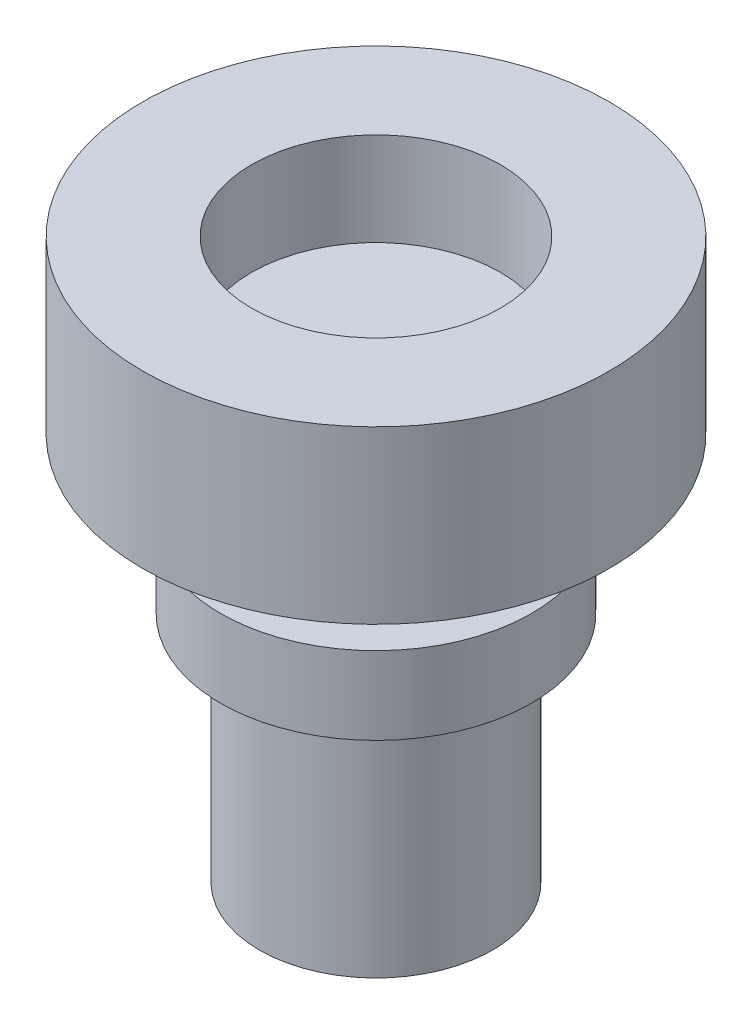
from build123d import *

# Parameters (mm, degrees)
SKETCH1_R           = 3
SKETCH1_R_2         = 1.6
BOSS_EXTRUDE1_DEPTH = 2.2
SKETCH1_3_R         = 1.6
BOSS_EXTRUDE2_DEPTH = 1
SKETCH5_R           = 1.5
BOSS_EXTRUDE3_DEPTH = 1
SKETCH6_R           = 2
BOSS_EXTRUDE4_DEPTH = 1
SKETCH8_R           = 1.5
BOSS_EXTRUDE5_DEPTH = 3


with BuildPart() as part:
    # Sketch1 → Boss-Extrude1 (new body)
    with BuildSketch(Plane(origin=(0, 0, 0), x_dir=(1, 0, 0), z_dir=(0, 1, 0))):
        with Locations((-0.522013312, 0.511138034)):
            Circle(SKETCH1_R)
        with Locations((-0.522013312, 0.511138034)):
            Circle(SKETCH1_R_2, mode=Mode.SUBTRACT)
    extrude(amount=BOSS_EXTRUDE1_DEPTH)

    # Sketch1_3 → Boss-Extrude2 (add)
    with BuildSketch(Plane(origin=(0, 0, 0), x_dir=(1, 0, 0), z_dir=(0, 1, 0))):
        with Locations((-0.522013312, 0.511138034)):
            Circle(SKETCH1_3_R)
    extrude(amount=BOSS_EXTRUDE2_DEPTH)

    # Sketch5 → Boss-Extrude3 (add)
    with BuildSketch(Plane.XZ):
        with Locations((-0.522013312, -0.511138034)):
            Circle(SKETCH5_R)
    extrude(amount=BOSS_EXTRUDE3_DEPTH)

    # Sketch6 → Boss-Extrude4 (add)
    with BuildSketch(Plane.XZ.offset(1)):
        with Locations((-0.522013312, -0.511138034)):
            Circle(SKETCH6_R)
    extrude(amount=BOSS_EXTRUDE4_DEPTH)

    # Sketch8 → Boss-Extrude5 (add)
    with BuildSketch(Plane(origin=(0, -2, 0), x_dir=(-1, 0, 0), z_dir=(0, -1, 0))):
        with Locations((0.522013312, 0.511138034)):
            Circle(SKETCH8_R)
    extrude(amount=BOSS_EXTRUDE5_DEPTH)


solid = part.part
